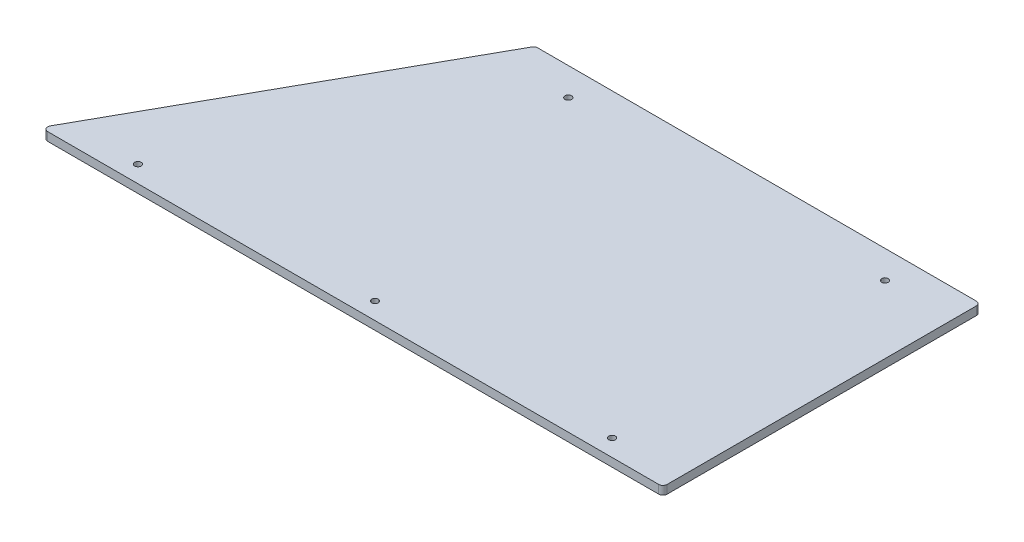
from build123d import *

# Parameters (mm, degrees)
SKETCH1_R           = 2.45745
BOSS_EXTRUDE1_DEPTH = 6.35
FILLET1_R           = 3.175


with BuildPart() as part:
    # Sketch1 → Boss-Extrude1 (new body)
    with BuildSketch(Plane(origin=(0, 0, 0), x_dir=(1, 0, 0), z_dir=(0, 1, 0))):
        Polygon((0, 0), (132.810986877, 238.125), (466.725, 238.125), (466.725, 0), align=None)
        with Locations((415.925, 217.297)):
            Circle(SKETCH1_R, mode=Mode.SUBTRACT)
        with Locations((415.925, 12.7)):
            Circle(SKETCH1_R, mode=Mode.SUBTRACT)
        with Locations((238.125, 12.7)):
            Circle(SKETCH1_R, mode=Mode.SUBTRACT)
        with Locations((60.325, 12.7)):
            Circle(SKETCH1_R, mode=Mode.SUBTRACT)
        with Locations((178.449400022, 217.297)):
            Circle(SKETCH1_R, mode=Mode.SUBTRACT)
    extrude(amount=BOSS_EXTRUDE1_DEPTH)

    # Fillet1
    fillet1_edges = [part.edges().sort_by_distance(p)[0] for p in [
        (0, 3.175, 0),
        (132.810986877, 3.175, -238.125),
        (466.725, 3.175, -238.125),
        (466.725, 3.175, 0),
    ]]
    fillet(fillet1_edges, radius=FILLET1_R)


solid = part.part
